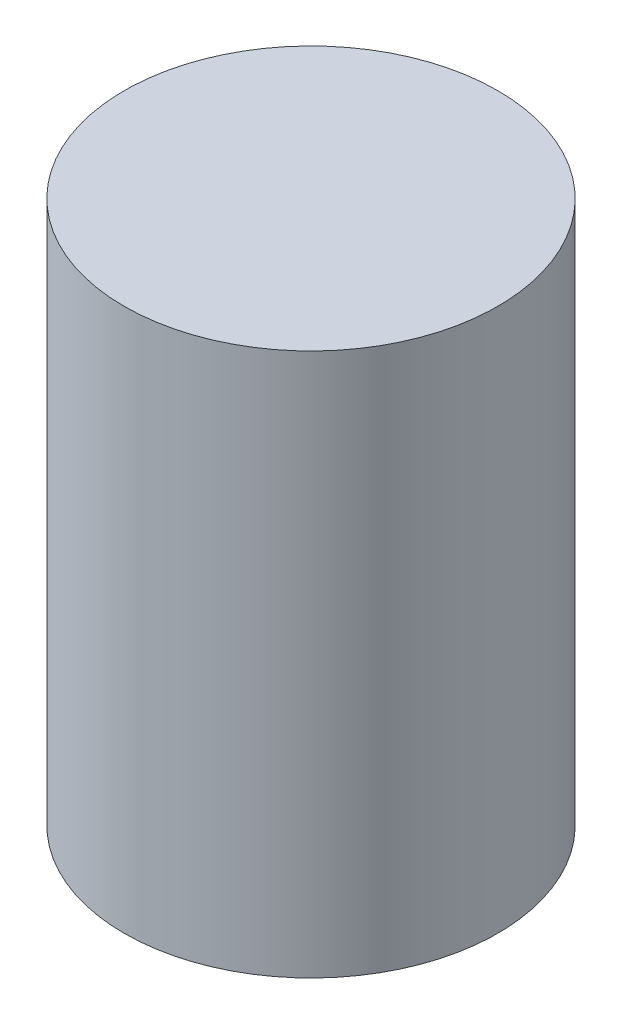
from build123d import *

# Parameters (mm, degrees)
SKETCH1_R           = 1.0922
BOSS_EXTRUDE1_DEPTH = 1.5875


with BuildPart() as part:
    # Sketch1 → Boss-Extrude1 (new body, symmetric)
    with BuildSketch(Plane(origin=(0, 0, 0), x_dir=(1, 0, 0), z_dir=(0, 1, 0))):
        with Locations(Location((0, 0, 0), (0, 0, 270))):  # turned: the seam where the file's is
            Circle(SKETCH1_R)
    extrude(amount=BOSS_EXTRUDE1_DEPTH, both=True)


solid = part.part
